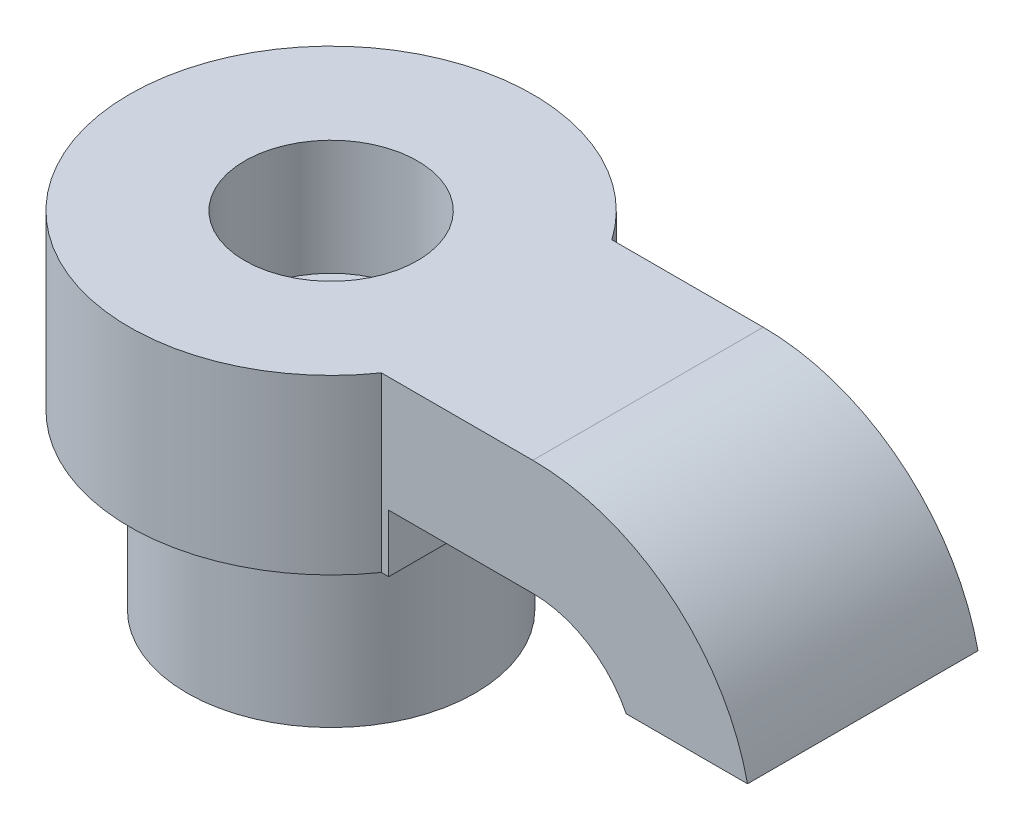
from build123d import *

# Parameters (mm, degrees)
EXTRUDE_1_DEPTH           = 8
EXTRUDE_2_DEPTH           = 6
SKETCH_5_R                = 5
EXTRUDE_3_DEPTH           = 6
HOLE_WIZARD_1_D           = 3
HOLE_WIZARD_1_DEPTH       = 30
HOLE_WIZARD_1_CBORE_D     = 6
HOLE_WIZARD_1_CBORE_DEPTH = 4


with BuildPart() as part:
    # 草图3 → 凸台-拉伸1 (new body)
    with BuildSketch(Plane.XY):
        with BuildLine():
            Line((0, 0), (5, 0))
            ThreePointArc((5, 0), (9.784396345, -1.68635165), (12.453978369, -6))
            Line((12.453978369, -6), (8.243547108, -6))
            ThreePointArc((8.243547108, -6), (6.905295111, -4.540192237), (5, -4))
            Line((5, -4), (0, -4))
            Line((0, -4), (0, 0))
        make_face()
    extrude(amount=EXTRUDE_1_DEPTH)

    # 草图4 → 凸台-拉伸2 (add)
    with BuildSketch(Plane(origin=(0, 0, 0), x_dir=(1, 0, 0), z_dir=(0, 1, 0))):
        with BuildLine():
            Line((-0.255437353, 0), (0, 0))
            Line((0, 0), (0, -8))
            Line((0, -8), (-0.255437353, -8))
            ThreePointArc((-0.255437353, -8), (-13, -4), (-0.255437353, 0))
        make_face()
    extrude(amount=-EXTRUDE_2_DEPTH)

    # 草图5 → 凸台-拉伸3 (add)
    with BuildSketch(Plane.XZ.offset(6)):
        with Locations((-6, 4)):
            Circle(SKETCH_5_R)
    extrude(amount=EXTRUDE_3_DEPTH)

    # 孔1
    with Locations(Plane(origin=(-6, 0, 4), x_dir=(0, 0, 1), z_dir=(0, 1, 0))):
        with Locations((0, 0)):
            CounterBoreHole(HOLE_WIZARD_1_D / 2, HOLE_WIZARD_1_CBORE_D / 2, HOLE_WIZARD_1_CBORE_DEPTH, depth=HOLE_WIZARD_1_DEPTH)


solid = part.part
